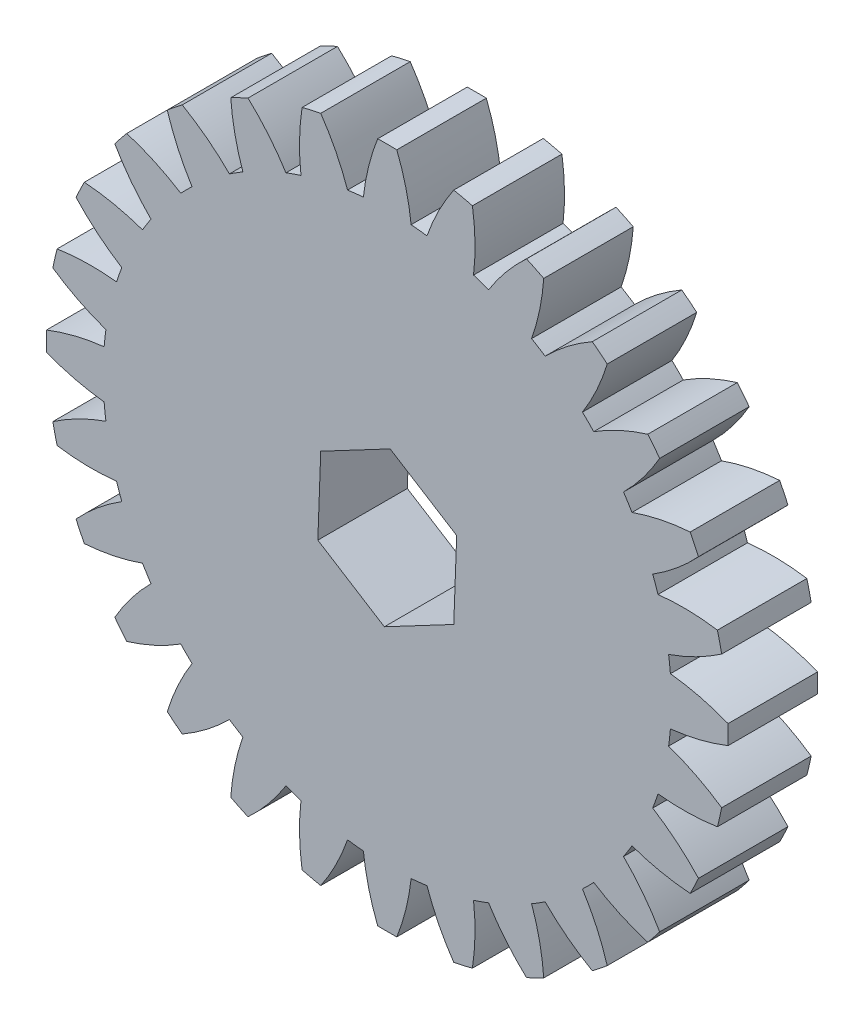
from build123d import *

# Parameters (mm, degrees)
BOSS_EXTRUDE1_DEPTH = 5


with BuildPart() as part:
    # Sketch1 → Boss-Extrude1 (new body)
    with BuildSketch(Plane.XY.offset(5)):
        with BuildLine():
            ThreePointArc((-4.820868329, 15.125305073), (-5.243180109, 14.984147869), (-5.661366831, 14.831201927))
            ThreePointArc((-5.661366831, 14.831201927), (-6.63581244, 16.180559962), (-7.780863095, 17.388521199))
            ThreePointArc((-7.780863095, 17.388521199), (-8.26548523, 17.163456934), (-8.743604518, 16.924889365))
            ThreePointArc((-8.743604518, 16.924889365), (-8.513109799, 15.276501202), (-8.065696106, 13.673337973))
            ThreePointArc((-8.065696106, 13.673337973), (-8.446009215, 13.441746663), (-8.819677449, 13.199580095))
            ThreePointArc((-8.819677449, 13.199580095), (-10.069952083, 14.29827236), (-11.455090589, 15.221149746))
            ThreePointArc((-11.455090589, 15.221149746), (-11.877480725, 14.893889741), (-12.290526286, 14.554912009))
            ThreePointArc((-12.290526286, 14.554912009), (-11.699009678, 12.999142279), (-10.906076201, 11.535732612))
            ThreePointArc((-10.906076201, 11.535732612), (-11.225320151, 11.225320151), (-11.535732612, 10.906076201))
            ThreePointArc((-11.535732612, 10.906076201), (-12.999142279, 11.699009678), (-14.554912009, 12.290526286))
            ThreePointArc((-14.554912009, 12.290526286), (-14.893889741, 11.877480725), (-15.221149746, 11.455090589))
            ThreePointArc((-15.221149746, 11.455090589), (-14.29827236, 10.069952083), (-13.199580095, 8.819677449))
            ThreePointArc((-13.199580095, 8.819677449), (-13.441746663, 8.446009215), (-13.673337973, 8.065696106))
            ThreePointArc((-13.673337973, 8.065696106), (-15.276501202, 8.513109799), (-16.924889365, 8.743604518))
            ThreePointArc((-16.924889365, 8.743604518), (-17.163456934, 8.26548523), (-17.388521199, 7.780863095))
            ThreePointArc((-17.388521199, 7.780863095), (-16.180559962, 6.63581244), (-14.831201927, 5.661366831))
            ThreePointArc((-14.831201927, 5.661366831), (-14.984147869, 5.243180109), (-15.125305073, 4.820868329))
            ThreePointArc((-15.125305073, 4.820868329), (-16.787832566, 4.900327047), (-18.446182096, 4.758241909))
            ThreePointArc((-18.446182096, 4.758241909), (-18.572376727, 4.239023792), (-18.683959592, 3.716470634))
            ThreePointArc((-18.683959592, 3.716470634), (-17.251486724, 2.868925453), (-15.719125365, 2.21917164))
            ThreePointArc((-15.719125365, 2.21917164), (-15.775181332, 1.777436058), (-15.818826219, 1.334302083))
            ThreePointArc((-15.818826219, 1.334302083), (-17.457351905, 1.041821436), (-19.042506233, 0.534281182))
            ThreePointArc((-19.042506233, 0.534281182), (-19.05, 0), (-19.042506233, -0.534281182))
            ThreePointArc((-19.042506233, -0.534281182), (-17.457351905, -1.041821436), (-15.818826219, -1.334302083))
            ThreePointArc((-15.818826219, -1.334302083), (-15.775181332, -1.777436058), (-15.719125365, -2.21917164))
            ThreePointArc((-15.719125365, -2.21917164), (-17.251486724, -2.868925453), (-18.683959592, -3.716470634))
            ThreePointArc((-18.683959592, -3.716470634), (-18.572376727, -4.239023792), (-18.446182096, -4.758241909))
            ThreePointArc((-18.446182096, -4.758241909), (-16.787832566, -4.900327047), (-15.125305073, -4.820868329))
            ThreePointArc((-15.125305073, -4.820868329), (-14.984147869, -5.243180109), (-14.831201927, -5.661366831))
            ThreePointArc((-14.831201927, -5.661366831), (-16.180559962, -6.63581244), (-17.388521199, -7.780863095))
            ThreePointArc((-17.388521199, -7.780863095), (-17.163456934, -8.26548523), (-16.924889365, -8.743604518))
            ThreePointArc((-16.924889365, -8.743604518), (-15.276501202, -8.513109799), (-13.673337973, -8.065696106))
            ThreePointArc((-13.673337973, -8.065696106), (-13.441746663, -8.446009215), (-13.199580095, -8.819677449))
            ThreePointArc((-13.199580095, -8.819677449), (-14.29827236, -10.069952083), (-15.221149746, -11.455090589))
            ThreePointArc((-15.221149746, -11.455090589), (-14.893889741, -11.877480725), (-14.554912009, -12.290526286))
            ThreePointArc((-14.554912009, -12.290526286), (-12.999142279, -11.699009678), (-11.535732612, -10.906076201))
            ThreePointArc((-11.535732612, -10.906076201), (-11.225320151, -11.225320151), (-10.906076201, -11.535732612))
            ThreePointArc((-10.906076201, -11.535732612), (-11.699009678, -12.999142279), (-12.290526286, -14.554912009))
            ThreePointArc((-12.290526286, -14.554912009), (-11.877480725, -14.893889741), (-11.455090589, -15.221149746))
            ThreePointArc((-11.455090589, -15.221149746), (-10.069952083, -14.29827236), (-8.819677449, -13.199580095))
            ThreePointArc((-8.819677449, -13.199580095), (-8.446009215, -13.441746663), (-8.065696106, -13.673337973))
            ThreePointArc((-8.065696106, -13.673337973), (-8.513109799, -15.276501202), (-8.743604518, -16.924889365))
            ThreePointArc((-8.743604518, -16.924889365), (-8.26548523, -17.163456934), (-7.780863095, -17.388521199))
            ThreePointArc((-7.780863095, -17.388521199), (-6.63581244, -16.180559962), (-5.661366831, -14.831201927))
            ThreePointArc((-5.661366831, -14.831201927), (-5.243180109, -14.984147869), (-4.820868329, -15.125305073))
            ThreePointArc((-4.820868329, -15.125305073), (-4.900327047, -16.787832566), (-4.758241909, -18.446182096))
            ThreePointArc((-4.758241909, -18.446182096), (-4.239023792, -18.572376727), (-3.716470634, -18.683959592))
            ThreePointArc((-3.716470634, -18.683959592), (-2.868925453, -17.251486724), (-2.21917164, -15.719125365))
            ThreePointArc((-2.21917164, -15.719125365), (-1.777436058, -15.775181332), (-1.334302083, -15.818826219))
            ThreePointArc((-1.334302083, -15.818826219), (-1.041821436, -17.457351905), (-0.534281182, -19.042506233))
            ThreePointArc((-0.534281182, -19.042506233), (0, -19.05), (0.534281182, -19.042506233))
            ThreePointArc((0.534281182, -19.042506233), (1.041821436, -17.457351905), (1.334302083, -15.818826219))
            ThreePointArc((1.334302083, -15.818826219), (1.777436058, -15.775181332), (2.21917164, -15.719125365))
            ThreePointArc((2.21917164, -15.719125365), (2.868925453, -17.251486724), (3.716470634, -18.683959592))
            ThreePointArc((3.716470634, -18.683959592), (4.239023792, -18.572376727), (4.758241909, -18.446182096))
            ThreePointArc((4.758241909, -18.446182096), (4.900327047, -16.787832566), (4.820868329, -15.125305073))
            ThreePointArc((4.820868329, -15.125305073), (5.243180109, -14.984147869), (5.661366831, -14.831201927))
            ThreePointArc((5.661366831, -14.831201927), (6.63581244, -16.180559962), (7.780863095, -17.388521199))
            ThreePointArc((7.780863095, -17.388521199), (8.26548523, -17.163456934), (8.743604518, -16.924889365))
            ThreePointArc((8.743604518, -16.924889365), (8.513109799, -15.276501202), (8.065696106, -13.673337973))
            ThreePointArc((8.065696106, -13.673337973), (8.446009215, -13.441746663), (8.819677449, -13.199580095))
            ThreePointArc((8.819677449, -13.199580095), (10.069952083, -14.29827236), (11.455090589, -15.221149746))
            ThreePointArc((11.455090589, -15.221149746), (11.877480725, -14.893889741), (12.290526286, -14.554912009))
            ThreePointArc((12.290526286, -14.554912009), (11.699009678, -12.999142279), (10.906076201, -11.535732612))
            ThreePointArc((10.906076201, -11.535732612), (11.225320151, -11.225320151), (11.535732612, -10.906076201))
            ThreePointArc((11.535732612, -10.906076201), (12.999142279, -11.699009678), (14.554912009, -12.290526286))
            ThreePointArc((14.554912009, -12.290526286), (14.893889741, -11.877480725), (15.221149746, -11.455090589))
            ThreePointArc((15.221149746, -11.455090589), (14.29827236, -10.069952083), (13.199580095, -8.819677449))
            ThreePointArc((13.199580095, -8.819677449), (13.441746663, -8.446009215), (13.673337973, -8.065696106))
            ThreePointArc((13.673337973, -8.065696106), (15.276501202, -8.513109799), (16.924889365, -8.743604518))
            ThreePointArc((16.924889365, -8.743604518), (17.163456934, -8.26548523), (17.388521199, -7.780863095))
            ThreePointArc((17.388521199, -7.780863095), (16.180559962, -6.63581244), (14.831201927, -5.661366831))
            ThreePointArc((14.831201927, -5.661366831), (14.984147869, -5.243180109), (15.125305073, -4.820868329))
            ThreePointArc((15.125305073, -4.820868329), (16.787832566, -4.900327047), (18.446182096, -4.758241909))
            ThreePointArc((18.446182096, -4.758241909), (18.572376727, -4.239023792), (18.683959592, -3.716470634))
            ThreePointArc((18.683959592, -3.716470634), (17.251486724, -2.868925453), (15.719125365, -2.21917164))
            ThreePointArc((15.719125365, -2.21917164), (15.775181332, -1.777436058), (15.818826219, -1.334302083))
            ThreePointArc((15.818826219, -1.334302083), (17.457351905, -1.041821436), (19.042506233, -0.534281182))
            ThreePointArc((19.042506233, -0.534281182), (19.05, 0), (19.042506233, 0.534281182))
            ThreePointArc((19.042506233, 0.534281182), (17.457351905, 1.041821436), (15.818826219, 1.334302083))
            ThreePointArc((15.818826219, 1.334302083), (15.775181332, 1.777436058), (15.719125365, 2.21917164))
            ThreePointArc((15.719125365, 2.21917164), (17.251486724, 2.868925453), (18.683959592, 3.716470634))
            ThreePointArc((18.683959592, 3.716470634), (18.572376727, 4.239023792), (18.446182096, 4.758241909))
            ThreePointArc((18.446182096, 4.758241909), (16.787832566, 4.900327047), (15.125305073, 4.820868329))
            ThreePointArc((15.125305073, 4.820868329), (14.984147869, 5.243180109), (14.831201927, 5.661366831))
            ThreePointArc((14.831201927, 5.661366831), (16.180559962, 6.63581244), (17.388521199, 7.780863095))
            ThreePointArc((17.388521199, 7.780863095), (17.163456934, 8.26548523), (16.924889365, 8.743604518))
            ThreePointArc((16.924889365, 8.743604518), (15.276501202, 8.513109799), (13.673337973, 8.065696106))
            ThreePointArc((13.673337973, 8.065696106), (13.441746663, 8.446009215), (13.199580095, 8.819677449))
            ThreePointArc((13.199580095, 8.819677449), (14.29827236, 10.069952083), (15.221149746, 11.455090589))
            ThreePointArc((15.221149746, 11.455090589), (14.893889741, 11.877480725), (14.554912009, 12.290526286))
            ThreePointArc((14.554912009, 12.290526286), (12.999142279, 11.699009678), (11.535732612, 10.906076201))
            ThreePointArc((11.535732612, 10.906076201), (11.225320151, 11.225320151), (10.906076201, 11.535732612))
            ThreePointArc((10.906076201, 11.535732612), (11.699009678, 12.999142279), (12.290526286, 14.554912009))
            ThreePointArc((12.290526286, 14.554912009), (11.877480725, 14.893889741), (11.455090589, 15.221149746))
            ThreePointArc((11.455090589, 15.221149746), (10.069952083, 14.29827236), (8.819677449, 13.199580095))
            ThreePointArc((8.819677449, 13.199580095), (8.446009215, 13.441746663), (8.065696106, 13.673337973))
            ThreePointArc((8.065696106, 13.673337973), (8.513109799, 15.276501202), (8.743604518, 16.924889365))
            ThreePointArc((8.743604518, 16.924889365), (8.26548523, 17.163456934), (7.780863095, 17.388521199))
            ThreePointArc((7.780863095, 17.388521199), (6.63581244, 16.180559962), (5.661366831, 14.831201927))
            ThreePointArc((5.661366831, 14.831201927), (5.243180109, 14.984147869), (4.820868329, 15.125305073))
            ThreePointArc((4.820868329, 15.125305073), (4.900327047, 16.787832566), (4.758241909, 18.446182096))
            ThreePointArc((4.758241909, 18.446182096), (4.239023792, 18.572376727), (3.716470634, 18.683959592))
            ThreePointArc((3.716470634, 18.683959592), (2.868925453, 17.251486724), (2.21917164, 15.719125365))
            ThreePointArc((2.21917164, 15.719125365), (1.777436058, 15.775181332), (1.334302083, 15.818826219))
            ThreePointArc((1.334302083, 15.818826219), (1.041821436, 17.457351905), (0.534281182, 19.042506233))
            ThreePointArc((0.534281182, 19.042506233), (0, 19.05), (-0.534281182, 19.042506233))
            ThreePointArc((-0.534281182, 19.042506233), (-1.041821436, 17.457351905), (-1.334302083, 15.818826219))
            ThreePointArc((-1.334302083, 15.818826219), (-1.777436058, 15.775181332), (-2.21917164, 15.719125365))
            ThreePointArc((-2.21917164, 15.719125365), (-2.868925453, 17.251486724), (-3.716470634, 18.683959592))
            ThreePointArc((-3.716470634, 18.683959592), (-4.239023792, 18.572376727), (-4.758241909, 18.446182096))
            ThreePointArc((-4.758241909, 18.446182096), (-4.900327047, 16.787832566), (-4.820868329, 15.125305073))
        make_face()
        Polygon((-3.716163133, 2.333123422), (-3.87862572, -2.051729967), (-0.162462587, -4.384853389), (3.716163133, -2.333123422), (3.87862572, 2.051729967), (0.162462587, 4.384853389), align=None, mode=Mode.SUBTRACT)
    extrude(amount=-BOSS_EXTRUDE1_DEPTH)


solid = part.part
